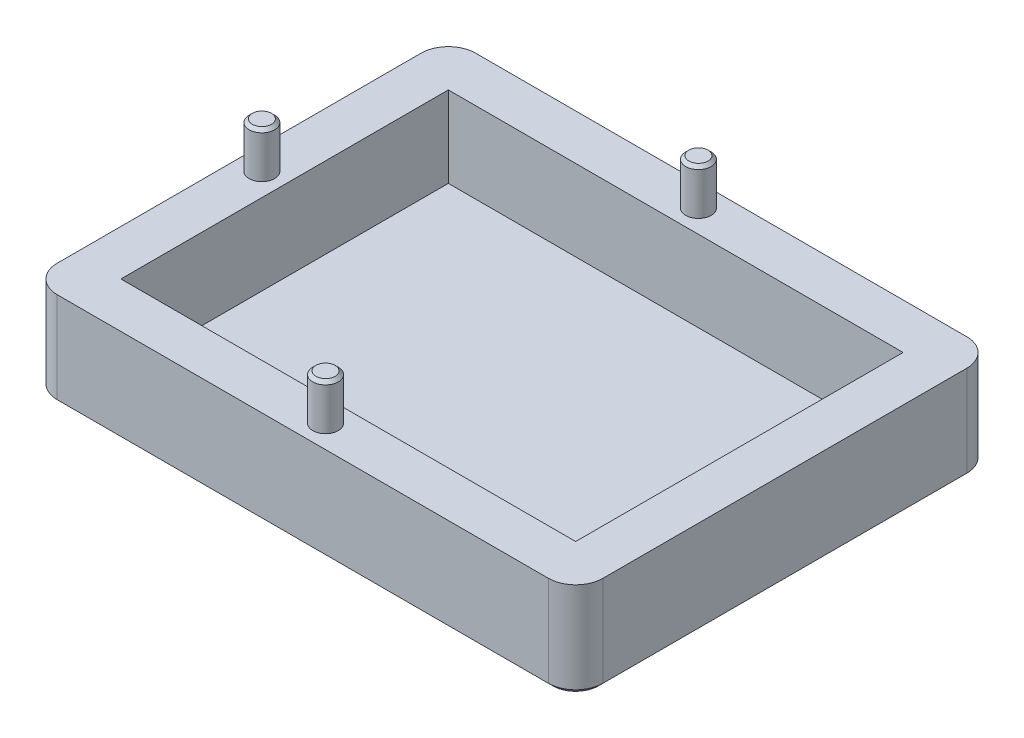
from build123d import *

# Parameters (mm, degrees)
SKETCH1_W           = 60
SKETCH1_H           = 46
SKETCH1_W_2         = 50
SKETCH1_H_2         = 36
BOSS_EXTRUDE1_DEPTH = 10.5
SKETCH2_W           = 50
SKETCH2_H           = 36
BOSS_EXTRUDE2_DEPTH = 1.6
FILLET1_R           = 3
SKETCH3_R           = 1.4
BOSS_EXTRUDE3_DEPTH = 5
CHAMFER1_SIZE       = 0.35
CHAMFER2_SIZE       = 0.5


with BuildPart() as part:
    # Sketch1 → Boss-Extrude1 (new body)
    with BuildSketch(Plane(origin=(0, 0, 0), x_dir=(1, 0, 0), z_dir=(0, 1, 0))):
        with Locations((25, 18)):
            Rectangle(SKETCH1_W, SKETCH1_H)
        with Locations((25, 18)):
            Rectangle(SKETCH1_W_2, SKETCH1_H_2, mode=Mode.SUBTRACT)
    extrude(amount=BOSS_EXTRUDE1_DEPTH)

    # Sketch2 → Boss-Extrude2 (add)
    with BuildSketch(Plane(origin=(0, 0, 0), x_dir=(1, 0, 0), z_dir=(0, 1, 0))):
        with Locations((25, 18)):
            Rectangle(SKETCH2_W, SKETCH2_H)
    extrude(amount=BOSS_EXTRUDE2_DEPTH)

    # Fillet1
    fillet1_edges = [part.edges().sort_by_distance(p)[0] for p in [
        (-5, 5.25, -41),
        (55, 5.25, -41),
        (55, 5.25, 5),
        (-5, 5.25, 5),
    ]]
    fillet(fillet1_edges, radius=FILLET1_R)

    # Sketch3 → Boss-Extrude3 (add)
    with BuildSketch(Plane(origin=(0, 10.5, 0), x_dir=(1, 0, 0), z_dir=(0, 1, 0))):
        with Locations((25, 38.5)):
            Circle(SKETCH3_R)
        with Locations((-2.5, 18)):
            Circle(SKETCH3_R)
        with Locations((25, -2.5)):
            Circle(SKETCH3_R)
    extrude(amount=BOSS_EXTRUDE3_DEPTH)

    # Chamfer1
    chamfer1_edges = [part.edges().sort_by_distance(p)[0] for p in [
        (23.6, 15.5, -38.5),
        (-3.9, 15.5, -18),
        (23.6, 15.5, 2.5),
    ]]
    chamfer(chamfer1_edges, length=CHAMFER1_SIZE)

    # Chamfer2
    chamfer2_edges = [part.edges().sort_by_distance(p)[0] for p in [
        (25, 0, -41),
        (-5, 0, -18),
        (55, 0, -18),
        (25, 0, 5),
        (-4.121320344, 0, 4.121320344),
        (54.121320344, 0, 4.121320344),
        (-4.121320344, 0, -40.121320344),
        (54.121320344, 0, -40.121320344),
    ]]
    chamfer(chamfer2_edges, length=CHAMFER2_SIZE)


solid = part.part
